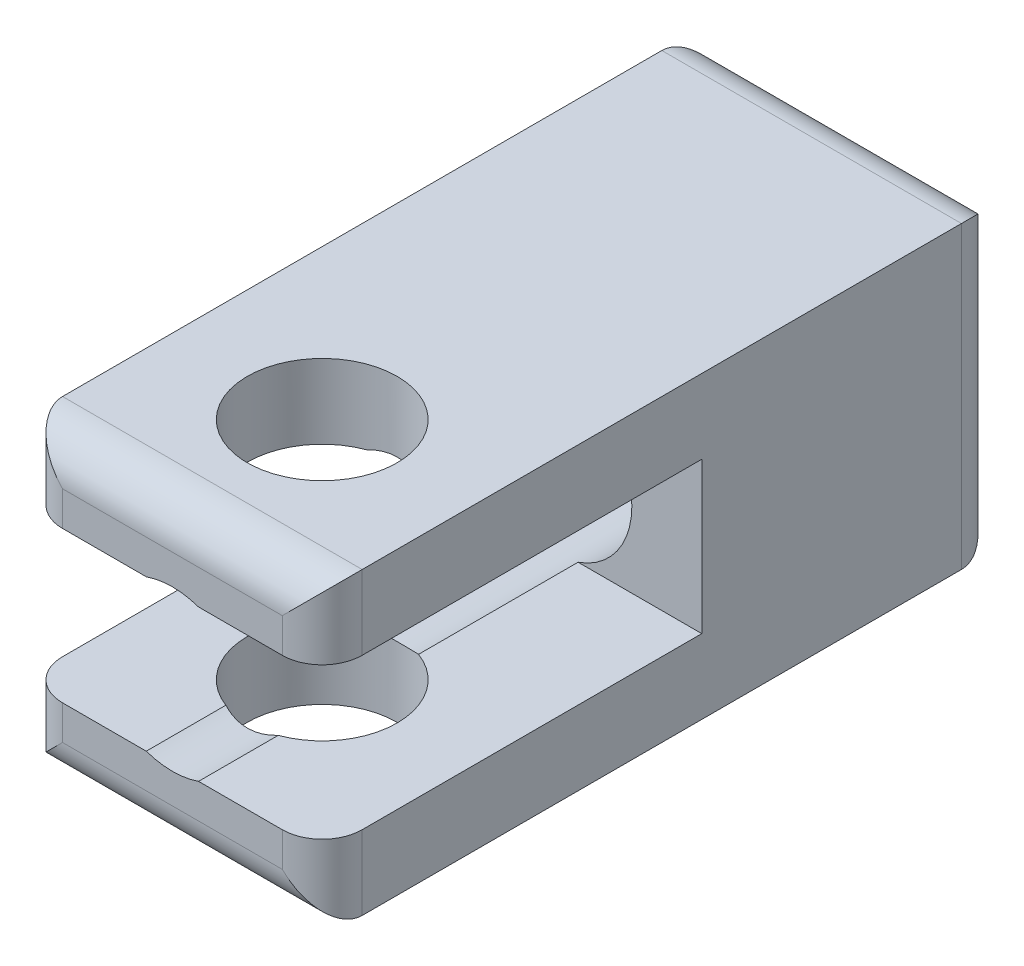
from build123d import *

# Parameters (mm, degrees)
SKETCH1_W           = 19.05
SKETCH1_H           = 19.05
BOSS_EXTRUDE1_DEPTH = 43.18
FILLET1_R           = 2.54
CUT_EXTRUDE1_REACH  = 45.18
SKETCH2_R           = 5.08
SKETCH3_W           = 43.18
SKETCH3_H           = 9.6012
CUT_EXTRUDE2_DEPTH  = 20.05
SKETCH4_R           = 4.7625
CUT_EXTRUDE3_DEPTH  = 20.05


with BuildPart() as part:
    # Sketch1 → Boss-Extrude1 (new body)
    with BuildSketch(Plane.XY):
        with Locations((9.525, 9.525)):
            Rectangle(SKETCH1_W, SKETCH1_H)
    extrude(amount=BOSS_EXTRUDE1_DEPTH)

    # Fillet1
    fillet1_edges = [part.edges().sort_by_distance(p)[0] for p in [
        (19.05, 9.525, 43.18),
        (9.525, 19.05, 43.18),
        (0, 9.525, 43.18),
        (9.525, 19.05, 0),
        (19.05, 9.525, 0),
        (9.525, 0, 0),
        (0, 9.525, 0),
        (9.525, 0, 43.18),
    ]]
    fillet(fillet1_edges, radius=FILLET1_R)

    # Sketch2 → Cut-Extrude1 (cut, up to next)
    with BuildSketch(Plane(origin=(0, 0, 0), x_dir=(-1, 0, 0), z_dir=(0, 0, -1)), mode=Mode.PRIVATE) as cut_extrude1_sk1:
        with Locations((-9.525, 9.525)):
            Circle(SKETCH2_R)
    cut_extrude1_tool1 = extrude(cut_extrude1_sk1.sketch, amount=-CUT_EXTRUDE1_REACH, mode=Mode.PRIVATE) & part.part
    add(cut_extrude1_tool1.solids().sort_by_distance((9.525, 9.525, 0))[0], mode=Mode.SUBTRACT)

    # Sketch3 → Cut-Extrude2 (cut, through all)
    with BuildSketch(Plane(origin=(19.05, 0, 0), x_dir=(0, 0, -1), z_dir=(1, 0, 0))):
        with Locations((-40.64, 9.525)):
            Rectangle(SKETCH3_W, SKETCH3_H)
    extrude(amount=-CUT_EXTRUDE2_DEPTH, mode=Mode.SUBTRACT)

    # Sketch4 → Cut-Extrude3 (cut, through all)
    with BuildSketch(Plane.XZ):
        with Locations((9.525, 33.655)):
            Circle(SKETCH4_R)
    extrude(amount=-CUT_EXTRUDE3_DEPTH, mode=Mode.SUBTRACT)


solid = part.part
